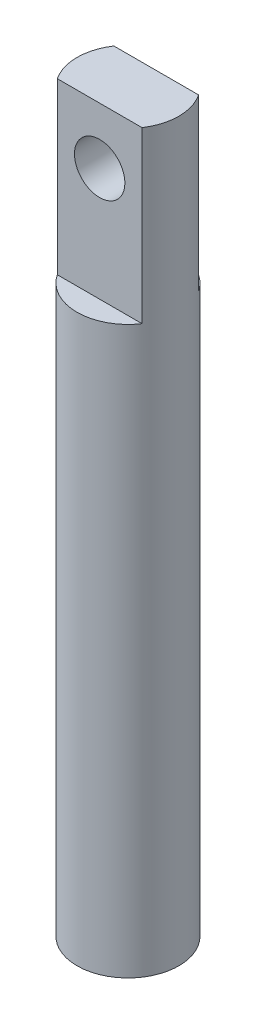
from build123d import *

# Parameters (mm, degrees)
SKETCH1_R                  = 2.286
EXTRUDE1_DEPTH             = 25.4
SKETCH2_W                  = 4.572
SKETCH2_H                  = 2.54
EXTRUDE2_DEPTH             = 7.62
SKETCH3_OUTSIDE_W          = 13.302
SKETCH3_OUTSIDE_H          = 13.302
SKETCH3_OUTSIDE_R          = 2.286
CUT_EXTRUDE1_DEPTH         = 7.62
TAP_DRILL_FOR_4_TAP1_D     = 2.2606
TAP_DRILL_FOR_4_TAP1_DEPTH = 6.35
TAP_DRILL_FOR_4_TAP1_TIP   = 0.679152758


with BuildPart() as part:
    # Sketch1 → Extrude1 (new body)
    with BuildSketch(Plane(origin=(0, 0, 0), x_dir=(1, 0, 0), z_dir=(0, 1, 0))):
        Circle(SKETCH1_R)
    extrude(amount=EXTRUDE1_DEPTH)

    # Sketch2 → Extrude2 (add)
    with BuildSketch(Plane(origin=(0, 25.4, 0), x_dir=(-1, 0, 0), z_dir=(0, 1, 0))):
        Rectangle(SKETCH2_W, SKETCH2_H)
    extrude(amount=EXTRUDE2_DEPTH)

    # Sketch3 outside → Cut-Extrude1 (cut)
    with BuildSketch(Plane(origin=(0, 25.4, 0), x_dir=(-1, 0, 0), z_dir=(0, 1, 0))):
        Rectangle(SKETCH3_OUTSIDE_W, SKETCH3_OUTSIDE_H)
        Circle(SKETCH3_OUTSIDE_R, mode=Mode.SUBTRACT)
    extrude(amount=CUT_EXTRUDE1_DEPTH, mode=Mode.SUBTRACT)

    # Tap Drill for #4 Tap1
    with Locations(Plane(origin=(-5.8e-08, 30.48, -1.27), x_dir=(-1, 0, 0), z_dir=(0, 0, -1))):
        with Locations((0, 0)):
            Hole(TAP_DRILL_FOR_4_TAP1_D / 2, depth=TAP_DRILL_FOR_4_TAP1_DEPTH)
            with Locations((0, 0, -(TAP_DRILL_FOR_4_TAP1_DEPTH + TAP_DRILL_FOR_4_TAP1_TIP / 2))):  # 118° drill point
                Cone(0, TAP_DRILL_FOR_4_TAP1_D / 2, TAP_DRILL_FOR_4_TAP1_TIP, mode=Mode.SUBTRACT)


solid = part.part
